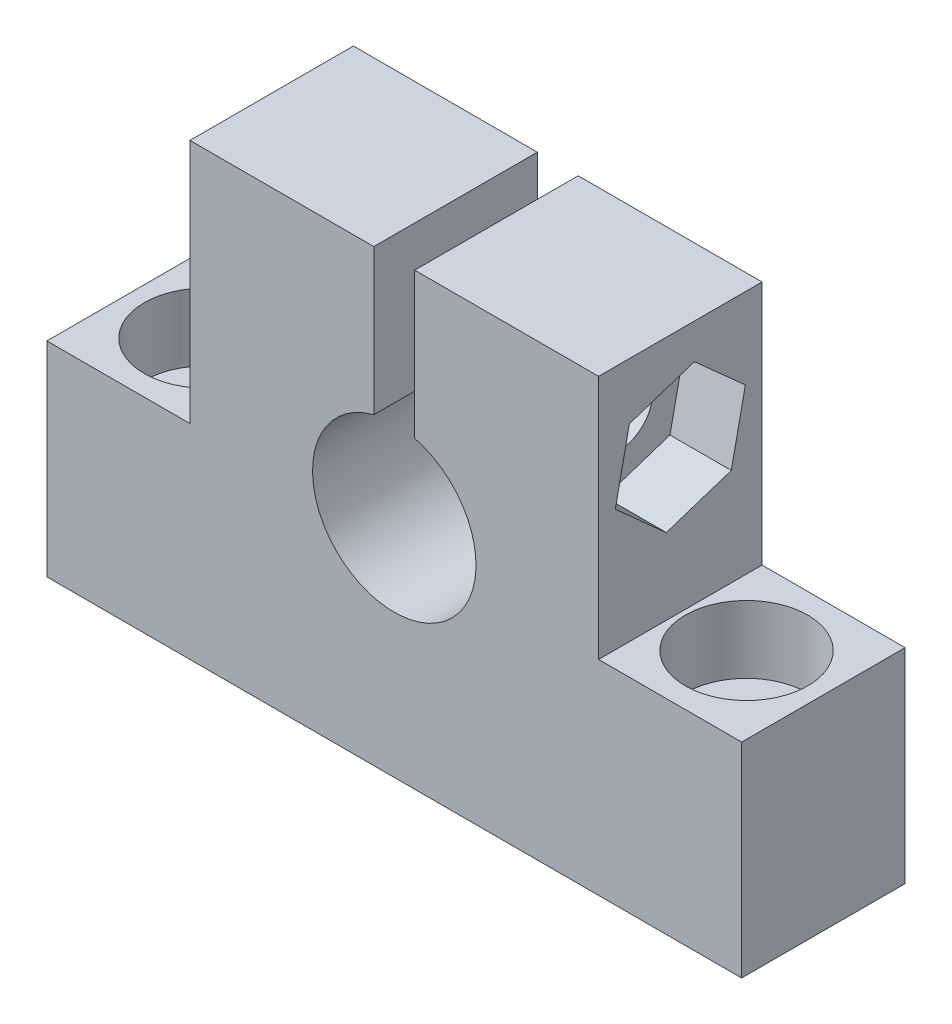
from build123d import *

# Parameters (mm, degrees)
EXTRUDE_1_DEPTH     = 8
CUT_EXTRUDE_1_DEPTH = 9
SKETCH_3_R          = 1.65
CUT_EXTRUDE_2_DEPTH = 28
SKETCH_4_R          = 3
CUT_EXTRUDE_3_DEPTH = 3.3
CUT_EXTRUDE_4_DEPTH = 3
SKETCH_6_R          = 1.65
CUT_EXTRUDE_5_DEPTH = 11
SKETCH_7_R          = 3
CUT_EXTRUDE_6_DEPTH = 3.3


with BuildPart() as part:
    # 草图1 → 凸台-拉伸1 (new body)
    with BuildSketch(Plane.XY):
        Polygon((-10, 22), (10, 22), (10, 10), (17, 10), (17, 0), (-17, 0), (-17, 10), (-10, 10), align=None)
    extrude(amount=EXTRUDE_1_DEPTH)

    # 草图2 → 切除-拉伸1 (cut, through all)
    with BuildSketch(Plane.XY.offset(8)):
        with BuildLine():
            Line((-1, 22), (1, 22))
            Line((1, 22), (1, 14.872983346))
            ThreePointArc((1, 14.872983346), (0, 7), (-1, 14.872983346))
            Line((-1, 14.872983346), (-1, 22))
        make_face()
    extrude(amount=-CUT_EXTRUDE_1_DEPTH, mode=Mode.SUBTRACT)

    # 草图3 → 切除-拉伸2 (cut, through all)
    with BuildSketch(Plane.ZY.offset(10)):
        with Locations((4, 17)):
            Circle(SKETCH_3_R)
    extrude(amount=-CUT_EXTRUDE_2_DEPTH, mode=Mode.SUBTRACT)

    # 草图4 → 切除-拉伸3 (cut)
    with BuildSketch(Plane.ZY.offset(10)):
        with Locations((4, 17)):
            Circle(SKETCH_4_R)
    extrude(amount=-CUT_EXTRUDE_3_DEPTH, mode=Mode.SUBTRACT)

    # 草图5 → 切除-拉伸4 (cut)
    with BuildSketch(Plane(origin=(10, 0, 0), x_dir=(0, 0, -1), z_dir=(1, 0, 0))):
        Polygon((-6.494110918, 19.234444912), (-7.182141516, 15.957259041), (-4.688030598, 13.72281413), (-1.505889082, 14.765555088), (-0.817858484, 18.042740959), (-3.311969402, 20.27718587), align=None)
    extrude(amount=-CUT_EXTRUDE_4_DEPTH, mode=Mode.SUBTRACT)

    # 草图6 → 切除-拉伸5 (cut, through all)
    with BuildSketch(Plane(origin=(0, 10, 0), x_dir=(1, 0, 0), z_dir=(0, 1, 0))):
        with Locations((-13.239613272, -4)):
            Circle(SKETCH_6_R)
        with Locations((13.239613272, -4)):
            Circle(SKETCH_6_R)
    extrude(amount=-CUT_EXTRUDE_5_DEPTH, mode=Mode.SUBTRACT)

    # 草图7 → 切除-拉伸6 (cut)
    with BuildSketch(Plane(origin=(0, 10, 0), x_dir=(1, 0, 0), z_dir=(0, 1, 0))):
        with Locations((13.239613272, -4)):
            Circle(SKETCH_7_R)
        with Locations((-13.239613272, -4)):
            Circle(SKETCH_7_R)
    extrude(amount=-CUT_EXTRUDE_6_DEPTH, mode=Mode.SUBTRACT)


solid = part.part
